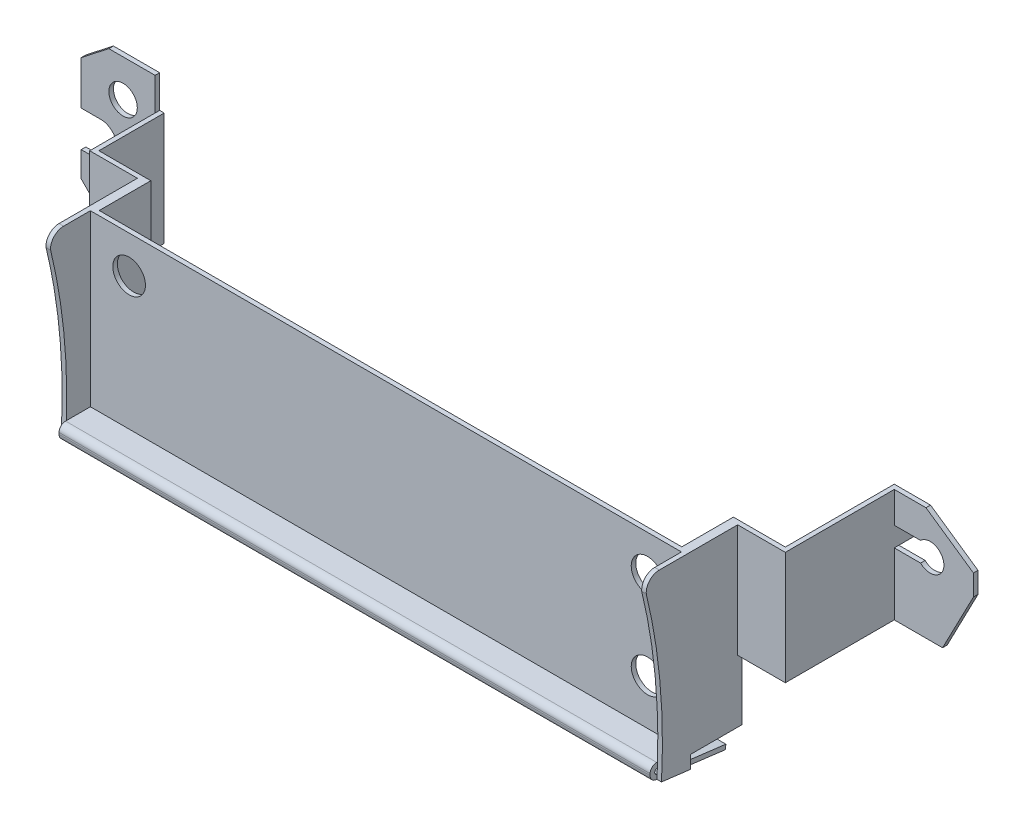
from build123d import *

# Parameters (mm, degrees)
SZKIC1_W                     = 90.5
SZKIC1_H                     = 26
DODANIE_WYCI_GNI_CIE1_DEPTH  = 0.7
DODANIE_WYCI_GNI_CIE2_DEPTH  = 90.5
DODANIE_WYCI_GNI_CIE3_DEPTH  = 0.7
DODANIE_WYCI_GNI_CIE4_DEPTH  = 0.7
SZKIC9_W                     = 1.35
SZKIC9_H                     = 26.839634362
DODANIE_WYCI_GNI_CIE5_DEPTH  = 7.9
DODANIE_WYCI_GNI_CIE6_DEPTH  = 17.3
DODANIE_WYCI_GNI_CIE7_DEPTH  = 17.3
WYTNIJ_WYCI_GNI_CIE1_START   = -0.7
WYTNIJ_WYCI_GNI_CIE1_DEPTH   = 0.7
SZKIC14_W                    = 0.7
SZKIC14_H                    = 3
DODANIE_WYCI_GNI_CIE8_DEPTH  = 3.15
DODANIE_WYCI_GNI_CIE9_DEPTH  = 0.7
SZKIC18_R                    = 2.175
WYTNIJ_WYCI_GNI_CIE2_DEPTH   = 0.7
SZKIC19_W                    = 8.5
SZKIC19_H                    = 2
DODANIE_WYCI_GNI_CIE10_DEPTH = 0.7
WYTNIJ_WYCI_GNI_CIE3_DEPTH   = 0.7
SZKIC22_W                    = 3.6
SZKIC22_H                    = 0.7
DODANIE_WYCI_GNI_CIE11_DEPTH = 3.3
SZKIC23_R                    = 2.5
WYTNIJ_WYCI_GNI_CIE4_DEPTH   = 0.7


with BuildPart() as part:
    # Szkic1 → Dodanie-wyciągnięcie1 (new body)
    with BuildSketch(Plane.XY):
        with Locations((8.895925444, -12.413393351)):
            Rectangle(SZKIC1_W, SZKIC1_H)
    extrude(amount=DODANIE_WYCI_GNI_CIE1_DEPTH)



with BuildPart() as body_2:
    # Szkic3 → Dodanie-wyciągnięcie2 (new body)
    with BuildSketch(Plane.ZY.offset(36.354074556)):
        with BuildLine():
            Line((5.5, -26.413393351), (5.5, -26.670245495))
            ThreePointArc((5.5, -26.670245495), (5.249678176, -27.332048058), (4.624034735, -27.662523372))
            Line((4.624034735, -27.662523372), (-6.01042337, -28.991830635))
            Line((-6.01042337, -28.991830635), (-6.097247684, -28.297236121))
            Line((-6.097247684, -28.297236121), (4.497633639, -26.977852669))
            ThreePointArc((4.497633639, -26.977852669), (4.713586161, -26.863878738), (4.8, -26.635497046))
            Line((4.8, -26.635497046), (4.8, -26.598027713))
            ThreePointArc((4.8, -26.598027713), (4.69895184, -26.354075874), (4.455, -26.253027713))
            Line((4.455, -26.253027713), (0, -26.253027713))
            Line((0, -26.253027713), (0, -25.413393351))
            Line((0, -25.413393351), (4.5, -25.413393351))
            ThreePointArc((4.5, -25.413393351), (5.207106781, -25.706286569), (5.5, -26.413393351))
        make_face()
    extrude(amount=-DODANIE_WYCI_GNI_CIE2_DEPTH)


with BuildPart() as part_1:
    add(part.part)

    add(body_2.part)  # Dodanie-wyciągnięcie3 merges body 2
    # Szkic4 → Dodanie-wyciągnięcie3 (add)
    with BuildSketch(Plane(origin=(54.145925444, 0, 0), x_dir=(0, 0, -1), z_dir=(1, 0, 0))):
        with BuildLine():
            Line((0, 0.586606649), (-4.796894469, 0.586606649))
            ThreePointArc((-4.796894469, 0.586606649), (-6.277718772, -0.069087068), (-6.787575884, -1.606233969))
            add(Edge.make_bspline(
                [(-4.469267418, -27.681869286), (-4.44254495, -27.204916247), (-4.010367743, -18.290006756), (-4.851145038, -9.610716303), (-6.787575884, -1.606233969)],
                knots=[-0.045928805, -0.045928805, -0.045928805, -0.045928805, 0, 0.813756029, 0.813756029, 0.813756029, 0.813756029], degree=3))
            Line((-4.469267418, -27.681869286), (0, -28.240527713))
            Line((0, -28.240527713), (0, 0.586606649))
        make_face()
    extrude(amount=DODANIE_WYCI_GNI_CIE3_DEPTH)

    # Szkic8 → Dodanie-wyciągnięcie4 (add)
    with BuildSketch(Plane.ZY.offset(36.354074556)):
        with BuildLine():
            Line((4.469267418, -27.681869286), (0, -28.240527713))
            Line((0, -28.240527713), (0, 0.586606649))
            Line((0, 0.586606649), (4.796894469, 0.586606649))
            ThreePointArc((4.796894469, 0.586606649), (6.277718772, -0.069087068), (6.787575884, -1.606233969))
            add(Edge.make_bspline(
                [(4.469267418, -27.681869286), (4.44254495, -27.204916247), (4.010367743, -18.290006756), (4.851145038, -9.610716303), (6.787575884, -1.606233969)],
                knots=[-0.045928805, -0.045928805, -0.045928805, -0.045928805, 0, 0.813756029, 0.813756029, 0.813756029, 0.813756029], degree=3))
        make_face()
    extrude(amount=DODANIE_WYCI_GNI_CIE4_DEPTH)

    # Szkic9 → Dodanie-wyciągnięcie5 (add)
    with BuildSketch(Plane(origin=(0, 0, 0), x_dir=(-1, 0, 0), z_dir=(0, 0, -1))):
        with Locations((-54.170925444, -12.833210532)):
            Rectangle(SZKIC9_W, SZKIC9_H)
        with Locations((36.379074556, -12.833210532)):
            Rectangle(SZKIC9_W, SZKIC9_H)
    extrude(amount=DODANIE_WYCI_GNI_CIE5_DEPTH)

    # Szkic11 → Dodanie-wyciągnięcie6 (add)
    with BuildSketch(Plane(origin=(0, 0.586606649, 0), x_dir=(1, 0, 0), z_dir=(0, 1, 0))):
        Polygon((-37.054074556, 7.9), (-37.054074556, 7.2), (-44.354074556, 7.2), (-44.354074556, 17.2), (-55.654074556, 17.2), (-55.654074556, 17.9), (-43.654074556, 17.9), (-43.654074556, 7.9), align=None)
    extrude(amount=-DODANIE_WYCI_GNI_CIE6_DEPTH)

    # Szkic12 → Dodanie-wyciągnięcie7 (add)
    with BuildSketch(Plane(origin=(0, 0.586606649, 0), x_dir=(1, 0, 0), z_dir=(0, 1, 0))):
        Polygon((54.845925444, 7.9), (54.845925444, 7.2), (62.145925444, 7.2), (62.145925444, 23.88), (74.265925444, 23.88), (74.265925444, 24.58), (61.445925444, 24.58), (61.445925444, 7.9), align=None)
    extrude(amount=-DODANIE_WYCI_GNI_CIE7_DEPTH)

    # Szkic13 → Wytnij-wyciągnięcie1 (cut)
    with BuildSketch(Plane.XY.offset(-23.88).offset(WYTNIJ_WYCI_GNI_CIE1_START)):
        Polygon((67.004736449, 0.586606649), (75.489507901, -5.272079996), (69.539548838, -16.713393351), (76.249870064, -16.713393351), (76.249870064, 0.586606649), align=None)
        with BuildLine():
            Line((62.145925444, -4.163393351), (66.176231598, -4.163393351))
            ThreePointArc((66.176231598, -4.163393351), (69.745925444, -5.663393351), (66.176231598, -7.163393351))
            Line((66.176231598, -7.163393351), (62.145925444, -7.163393351))
            Line((62.145925444, -7.163393351), (62.145925444, -4.163393351))
        make_face()
    extrude(amount=WYTNIJ_WYCI_GNI_CIE1_DEPTH, mode=Mode.SUBTRACT)

    # Szkic14 → Dodanie-wyciągnięcie8 (add)
    with BuildSketch(Plane(origin=(0, 0, -24.58), x_dir=(-1, 0, 0), z_dir=(0, 0, -1))):
        with Locations((-61.795925444, -5.663393351)):
            Rectangle(SZKIC14_W, SZKIC14_H)
    extrude(amount=DODANIE_WYCI_GNI_CIE8_DEPTH)

    # Szkic17 → Dodanie-wyciągnięcie9 (add)
    with BuildSketch(Plane.XY.offset(-17.2)):
        Polygon((-44.353275943, 0.54213061), (-55.654074556, 0.586606649), (-55.654074556, 5.586606649), (-44.353275943, 5.586606649), align=None)
    extrude(amount=-DODANIE_WYCI_GNI_CIE9_DEPTH)

    # Szkic18 → Wytnij-wyciągnięcie2 (cut)
    with BuildSketch(Plane.XY.offset(-17.2)):
        with Locations((-49.249074556, -0.088393351)):
            Circle(SZKIC18_R)
        Polygon((-51.424074556, 5.586606649), (-55.654074556, 2.286606649), (-55.654074556, 5.586606649), align=None)
        with BuildLine():
            Line((-55.654074556, -4.413393351), (-52.654074556, -4.413393351))
            ThreePointArc((-52.654074556, -4.413393351), (-50.886307603, -5.145626398), (-50.154074556, -6.913393351))
            Line((-50.154074556, -6.913393351), (-50.154074556, -7.413393351))
            ThreePointArc((-50.154074556, -7.413393351), (-50.886307603, -9.181160304), (-52.654074556, -9.913393351))
            Line((-52.654074556, -9.913393351), (-55.654074556, -9.913393351))
            Line((-55.654074556, -9.913393351), (-55.654074556, -4.413393351))
        make_face()
    extrude(amount=-WYTNIJ_WYCI_GNI_CIE2_DEPTH, mode=Mode.SUBTRACT)

    # Szkic19 → Dodanie-wyciągnięcie10 (add)
    with BuildSketch(Plane.XY.offset(-17.2)):
        with Locations((-51.404074556, -17.713393351)):
            Rectangle(SZKIC19_W, SZKIC19_H)
    extrude(amount=-DODANIE_WYCI_GNI_CIE10_DEPTH)

    # Szkic21 → Wytnij-wyciągnięcie3 (cut)
    with BuildSketch(Plane.XY.offset(-17.2)):
        Polygon((-55.654074556, -13.813393351), (-50.754074556, -18.713393351), (-55.654074556, -18.713393351), align=None)
    extrude(amount=-WYTNIJ_WYCI_GNI_CIE3_DEPTH, mode=Mode.SUBTRACT)

    # Szkic22 → Dodanie-wyciągnięcie11 (add)
    with BuildSketch(Plane(origin=(0, 0, -17.9), x_dir=(-1, 0, 0), z_dir=(0, 0, -1))):
        with Locations((48.954074556, -18.363393351)):
            Rectangle(SZKIC22_W, SZKIC22_H)
    extrude(amount=DODANIE_WYCI_GNI_CIE11_DEPTH)

    # Szkic23 → Wytnij-wyciągnięcie4 (cut)
    with BuildSketch(Plane(origin=(0, 0, 0), x_dir=(-1, 0, 0), z_dir=(0, 0, -1))):
        with Locations((-48.950925444, -5.101869726)):
            Circle(SZKIC23_R)
        with Locations((30.424074556, -5.101869726)):
            Circle(SZKIC23_R)
        with Locations((-48.950925444, -18.436869726)):
            Circle(SZKIC23_R)
    extrude(amount=-WYTNIJ_WYCI_GNI_CIE4_DEPTH, mode=Mode.SUBTRACT)


solid = part_1.part
